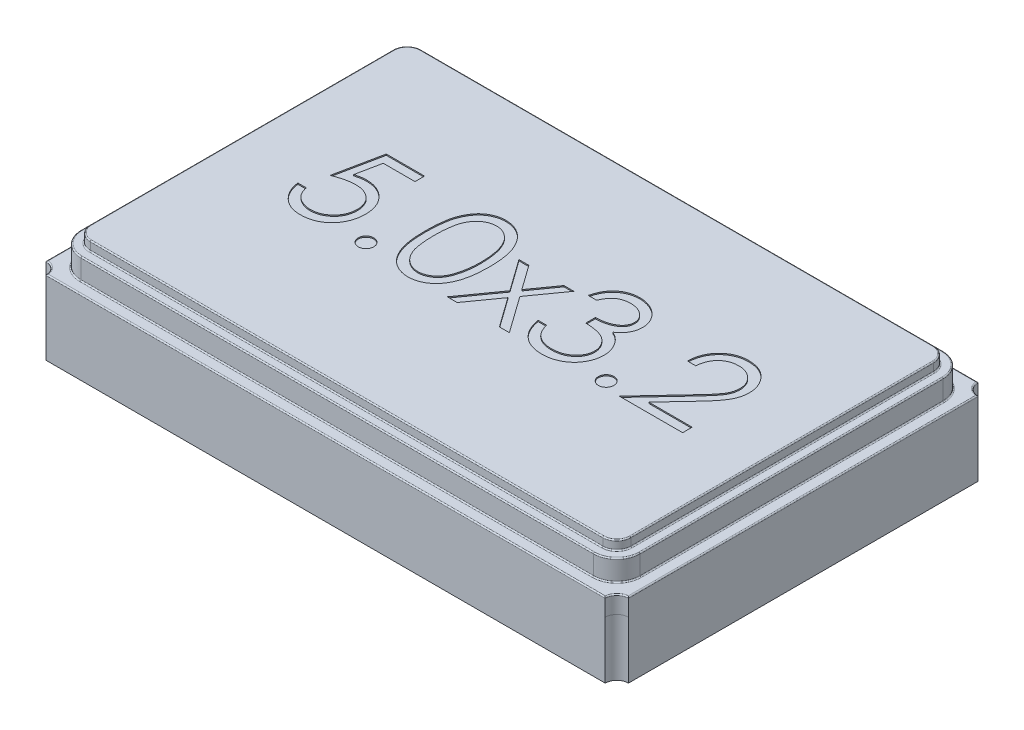
from build123d import *

# Parameters (mm, degrees)
BOSS_EXTRUDE1_DEPTH = 0.64
BOSS_EXTRUDE2_DEPTH = 0.18
BOSS_EXTRUDE3_DEPTH = 0.08
FILLET1_R           = 0.01
CUT_EXTRUDE1_DEPTH  = 0.01


with BuildPart() as part:
    # Sketch1 → Boss-Extrude1 (new body)
    with BuildSketch(Plane(origin=(0, 0, 0), x_dir=(1, 0, 0), z_dir=(0, 1, 0))):
        with BuildLine():
            Line((-2.4, 1.6), (2.4, 1.6))
            ThreePointArc((2.4, 1.6), (2.429289322, 1.529289322), (2.5, 1.5))
            Line((2.5, 1.5), (2.5, -1.5))
            ThreePointArc((2.5, -1.5), (2.429289322, -1.529289322), (2.4, -1.6))
            Line((2.4, -1.6), (-2.4, -1.6))
            ThreePointArc((-2.4, -1.6), (-2.429289322, -1.529289322), (-2.5, -1.5))
            Line((-2.5, -1.5), (-2.5, 1.5))
            ThreePointArc((-2.5, 1.5), (-2.429289322, 1.529289322), (-2.4, 1.6))
        make_face()
    extrude(amount=BOSS_EXTRUDE1_DEPTH)

    # Sketch2 → Boss-Extrude2 (add)
    with BuildSketch(Plane(origin=(0, 0.64, 0), x_dir=(1, 0, 0), z_dir=(0, 1, 0))):
        with BuildLine():
            Line((-2.2, 1.5), (2.2, 1.5))
            ThreePointArc((2.2, 1.5), (2.341421356, 1.441421356), (2.4, 1.3))
            Line((2.4, 1.3), (2.4, -1.3))
            ThreePointArc((2.4, -1.3), (2.341421356, -1.441421356), (2.2, -1.5))
            Line((2.2, -1.5), (-2.2, -1.5))
            ThreePointArc((-2.2, -1.5), (-2.341421356, -1.441421356), (-2.4, -1.3))
            Line((-2.4, -1.3), (-2.4, 1.3))
            ThreePointArc((-2.4, 1.3), (-2.341421356, 1.441421356), (-2.2, 1.5))
        make_face()
    extrude(amount=BOSS_EXTRUDE2_DEPTH)

    # Sketch4 → Boss-Extrude3 (add)
    with BuildSketch(Plane(origin=(0, 0.82, 0), x_dir=(1, 0, 0), z_dir=(0, 1, 0))):
        with BuildLine():
            Line((2.32, -1.3), (2.32, 1.3))
            ThreePointArc((2.32, 1.3), (2.284852814, 1.384852814), (2.2, 1.42))
            Line((2.2, 1.42), (-2.2, 1.42))
            ThreePointArc((-2.2, 1.42), (-2.284852814, 1.384852814), (-2.32, 1.3))
            Line((-2.32, 1.3), (-2.32, -1.3))
            ThreePointArc((-2.32, -1.3), (-2.284852814, -1.384852814), (-2.2, -1.42))
            Line((-2.2, -1.42), (2.2, -1.42))
            ThreePointArc((2.2, -1.42), (2.284852814, -1.384852814), (2.32, -1.3))
        make_face()
    extrude(amount=BOSS_EXTRUDE3_DEPTH)

    # Fillet1
    fillet1_edges = [part.edges().sort_by_distance(p)[0] for p in [
        (2.429289322, 0.64, -1.529289322),
        (0, 0.64, -1.6),
        (-2.429289322, 0.64, -1.529289322),
        (-2.5, 0.64, 0),
        (-2.429289322, 0.64, 1.529289322),
        (0, 0.64, 1.6),
        (2.341421356, 0.64, 1.441421356),
        (2.4, 0.64, 0),
        (2.341421356, 0.64, -1.441421356),
        (0, 0.64, -1.5),
        (-2.341421356, 0.64, -1.441421356),
        (-2.4, 0.64, 0),
        (-2.341421356, 0.64, 1.441421356),
        (0, 0.64, 1.5),
        (2.341421356, 0.82, 1.441421356),
        (2.4, 0.82, 0),
        (2.341421356, 0.82, -1.441421356),
        (0, 0.82, -1.5),
        (-2.341421356, 0.82, -1.441421356),
        (-2.4, 0.82, 0),
        (-2.341421356, 0.82, 1.441421356),
        (0, 0.82, 1.5),
        (2.429289322, 0.64, 1.529289322),
        (2.284852814, 0.82, 1.384852814),
        (2.32, 0.82, 0),
        (2.284852814, 0.82, -1.384852814),
        (0, 0.82, -1.42),
        (-2.284852814, 0.82, -1.384852814),
        (-2.32, 0.82, 0),
        (-2.284852814, 0.82, 1.384852814),
        (0, 0.82, 1.42),
        (2.284852814, 0.9, 1.384852814),
        (2.32, 0.9, 0),
        (2.284852814, 0.9, -1.384852814),
        (0, 0.9, -1.42),
        (-2.284852814, 0.9, -1.384852814),
        (-2.32, 0.9, 0),
        (-2.284852814, 0.9, 1.384852814),
        (0, 0.9, 1.42),
        (2.5, 0.64, 0),
    ]]
    fillet(fillet1_edges, radius=FILLET1_R)

    # Sketch8 → Cut-Extrude1 (cut)
    with BuildSketch(Plane(origin=(0, 0.9, 0), x_dir=(1, 0, 0), z_dir=(0, 1, 0))):
        with BuildLine():
            Line((-1.244778818, 0.493988522), (-1.244778818, 0.41193724))
            Line((-1.244778818, 0.41193724), (-1.516894202, 0.41193724))
            Line((-1.516894202, 0.41193724), (-1.560003177, 0.201520573))
            add(Edge.make_bspline(
                [(-1.560003177, 0.201520573), (-1.551533263, 0.203858921), (-1.535124144, 0.2083891), (-1.510904747, 0.21341899), (-1.487912243, 0.216451092), (-1.472992159, 0.216865106), (-1.465772408, 0.217065445)],
                knots=[0, 0, 0, 0, 1.100273476, 2.13160584, 3.095893838, 4, 4, 4, 4], degree=3))
            add(Edge.make_bspline(
                [(-1.465772408, 0.217065445), (-1.456838981, 0.216872088), (-1.439273633, 0.2164919), (-1.413573303, 0.212841192), (-1.38904007, 0.207094926), (-1.365725242, 0.199067378), (-1.343585688, 0.188802296), (-1.322825103, 0.175979452), (-1.303131865, 0.161000405), (-1.284859272, 0.143778688), (-1.268282288, 0.124825176), (-1.253707204, 0.104446234), (-1.241327184, 0.082839911), (-1.23137044, 0.059799772), (-1.223419735, 0.035580537), (-1.21812785, 0.009927375), (-1.214604031, -0.016917909), (-1.214210343, -0.03527324), (-1.214009587, -0.044633273)],
                knots=[0, 0, 0, 0, 1.052922333, 2.070308379, 3.05430497, 4.020497103, 4.973039431, 5.925935799, 6.892292201, 7.88610001, 8.88166317, 9.857072816, 10.836096531, 11.812156883, 12.81219415, 13.836441305, 14.89672472, 16, 16, 16, 16], degree=3))
            add(Edge.make_bspline(
                [(-1.214009587, -0.044633273), (-1.214161604, -0.051152638), (-1.214463584, -0.064103264), (-1.215999262, -0.083336224), (-1.218955997, -0.102162014), (-1.222925762, -0.120583132), (-1.228078315, -0.138564703), (-1.234315813, -0.156158195), (-1.241949191, -0.173254105), (-1.250322076, -0.190014196), (-1.259749843, -0.206059569), (-1.270213502, -0.221065051), (-1.281268471, -0.235255744), (-1.293163645, -0.248479455), (-1.306009587, -0.260649287), (-1.319650722, -0.271837466), (-1.3339782, -0.282233199), (-1.349213684, -0.2914145), (-1.365017681, -0.299863176), (-1.381618416, -0.30679427), (-1.398638005, -0.312990962), (-1.416321405, -0.317930283), (-1.434628562, -0.321800581), (-1.453589653, -0.32442929), (-1.473105235, -0.326343904), (-1.486333809, -0.326463757), (-1.493015997, -0.326524299)],
                knots=[0, 0, 0, 0, 1.056347294, 2.098418968, 3.122841568, 4.141288669, 5.149314143, 6.15115421, 7.162517403, 8.180376062, 9.185164535, 10.17417709, 11.141909838, 12.097768115, 13.052685741, 14.0056014, 14.954263652, 15.917497458, 16.885230207, 17.854509472, 18.828990115, 19.81800267, 20.826176721, 21.857883937, 22.917946725, 24, 24, 24, 24], degree=3))
            add(Edge.make_bspline(
                [(-1.493015997, -0.326524299), (-1.500987239, -0.326366393), (-1.516669714, -0.326055732), (-1.539645844, -0.322805793), (-1.561752039, -0.318151183), (-1.582810348, -0.311148607), (-1.603009494, -0.302374368), (-1.622077544, -0.291284958), (-1.640501721, -0.278718305), (-1.657533044, -0.26388851), (-1.673340156, -0.247679212), (-1.687490215, -0.230088894), (-1.700092175, -0.211407878), (-1.710944232, -0.191545443), (-1.720200922, -0.170553779), (-1.72747292, -0.148354236), (-1.733342258, -0.125062806), (-1.735825326, -0.109027718), (-1.73708651, -0.100883273)],
                knots=[0, 0, 0, 0, 1.0467383, 2.05933395, 3.04377827, 4.011590433, 4.970194871, 5.932262533, 6.905835911, 7.896367577, 8.894135286, 9.877477877, 10.858688626, 11.851381753, 12.8477658, 13.868841284, 14.917554742, 16, 16, 16, 16], degree=3))
            Line((-1.73708651, -0.100883273), (-1.665291638, -0.100883273))
            add(Edge.make_bspline(
                [(-1.665291638, -0.100883273), (-1.663525111, -0.108512177), (-1.660129747, -0.123175353), (-1.652677005, -0.143776802), (-1.643564805, -0.162135482), (-1.632729525, -0.178494244), (-1.619803804, -0.192759157), (-1.60505422, -0.205471629), (-1.588517597, -0.21694023), (-1.570142002, -0.226499719), (-1.550756155, -0.234652577), (-1.530466507, -0.240081536), (-1.509825514, -0.243898883), (-1.495864744, -0.244281), (-1.488849331, -0.244473017)],
                knots=[0, 0, 0, 0, 1.136247022, 2.183929868, 3.172523383, 4.106158343, 5.02341133, 5.958108904, 6.928429099, 7.938127109, 8.96079061, 9.975095812, 10.982467395, 12, 12, 12, 12], degree=3))
            add(Edge.make_bspline(
                [(-1.488849331, -0.244473017), (-1.482001686, -0.244285411), (-1.468518618, -0.243916012), (-1.448676016, -0.241072809), (-1.429518787, -0.236693936), (-1.411235963, -0.230140826), (-1.393507611, -0.222176319), (-1.376782178, -0.21195573), (-1.360575806, -0.20019344), (-1.345392232, -0.186717639), (-1.331486073, -0.171867423), (-1.319198959, -0.155986876), (-1.308964236, -0.139045883), (-1.300339297, -0.121337733), (-1.293789972, -0.102668349), (-1.289117747, -0.083125223), (-1.286374191, -0.062660085), (-1.285996778, -0.048701386), (-1.285804459, -0.041588402)],
                knots=[0, 0, 0, 0, 1.027316725, 2.022795036, 3.002884548, 3.971462791, 4.93288096, 5.914575861, 6.907176829, 7.935150275, 8.956128384, 9.956726525, 10.942570165, 11.921478529, 12.907843606, 13.90538589, 14.932640048, 16, 16, 16, 16], degree=3))
            add(Edge.make_bspline(
                [(-1.285804459, -0.041588402), (-1.285954968, -0.035171087), (-1.28624957, -0.022610106), (-1.288656557, -0.004233145), (-1.292843294, 0.013154979), (-1.298654466, 0.029638232), (-1.306032639, 0.045232162), (-1.315048939, 0.059952862), (-1.325872573, 0.073606309), (-1.338236433, 0.086198893), (-1.351781128, 0.097820579), (-1.366739698, 0.107727798), (-1.38279911, 0.116062408), (-1.399765876, 0.123255093), (-1.418043567, 0.128420978), (-1.437270226, 0.132299352), (-1.457653473, 0.134542863), (-1.47158963, 0.134854152), (-1.478753177, 0.135014163)],
                knots=[0, 0, 0, 0, 1.045622112, 2.046656509, 3.013763289, 3.955457236, 4.890082067, 5.820317437, 6.762574623, 7.722996705, 8.69280354, 9.665887285, 10.63943826, 11.638615906, 12.663482002, 13.728887084, 14.832589034, 16, 16, 16, 16], degree=3))
            add(Edge.make_bspline(
                [(-1.478753177, 0.135014163), (-1.484954075, 0.134881456), (-1.497757356, 0.134607451), (-1.517396859, 0.132589966), (-1.538034967, 0.12933527), (-1.559592566, 0.124858413), (-1.582134397, 0.118999881), (-1.605612888, 0.111979424), (-1.630077407, 0.103585824), (-1.646561458, 0.097247033), (-1.655035228, 0.093988522)],
                knots=[0, 0, 0, 0, 0.817624296, 1.688186739, 2.600797293, 3.572016777, 4.590301741, 5.671205678, 6.80286297, 8, 8, 8, 8], degree=3))
            Line((-1.655035228, 0.093988522), (-1.572983946, 0.493988522))
            Line((-1.572983946, 0.493988522), (-1.244778818, 0.493988522))
        make_face()
        with BuildLine():
            add(Edge.make_bspline(
                [(-1.003753177, -0.182934555), (-0.999298271, -0.183199279), (-0.99056495, -0.183718239), (-0.977938863, -0.187278622), (-0.966511512, -0.193600601), (-0.956332713, -0.202026379), (-0.947942662, -0.212242531), (-0.941395381, -0.223578739), (-0.937866013, -0.236310531), (-0.937350833, -0.245094457), (-0.93708651, -0.249601222)],
                knots=[0, 0, 0, 0, 1.020151414, 1.999887582, 2.974338812, 3.990962822, 5.007586832, 5.987933904, 6.967670073, 8, 8, 8, 8], degree=3))
            add(Edge.make_bspline(
                [(-0.93708651, -0.249601222), (-0.93735979, -0.253999697), (-0.937898695, -0.262673426), (-0.941387291, -0.275309189), (-0.94799256, -0.286652482), (-0.956274844, -0.297007256), (-0.966514029, -0.305450884), (-0.977965879, -0.311719077), (-0.99053531, -0.315534386), (-0.999293326, -0.316020397), (-1.003753177, -0.316267889)],
                knots=[0, 0, 0, 0, 1.009421747, 1.99056486, 2.972319754, 3.999869655, 5.017953583, 5.993804169, 6.978383603, 8, 8, 8, 8], degree=3))
            add(Edge.make_bspline(
                [(-1.003753177, -0.316267889), (-1.008216241, -0.316029352), (-1.016929311, -0.315563666), (-1.029451824, -0.311640739), (-1.040973417, -0.305509663), (-1.051210608, -0.296991512), (-1.059562259, -0.286705765), (-1.065876632, -0.275231069), (-1.069668666, -0.262709597), (-1.07016738, -0.254006822), (-1.070419844, -0.249601222)],
                knots=[0, 0, 0, 0, 1.022052826, 1.995314843, 2.982371812, 4.00089066, 5.028879526, 6.005146991, 6.990147033, 8, 8, 8, 8], degree=3))
            add(Edge.make_bspline(
                [(-1.070419844, -0.249601222), (-1.070177078, -0.245087078), (-1.069703108, -0.236273766), (-1.065868671, -0.223656827), (-1.059611252, -0.212189755), (-1.051152876, -0.202041966), (-1.040975894, -0.193542011), (-1.029479618, -0.187355772), (-1.016899152, -0.183689392), (-1.008211166, -0.183190531), (-1.003753177, -0.182934555)],
                knots=[0, 0, 0, 0, 1.032775665, 2.016367738, 2.991239715, 4.008302682, 5.025365648, 6.011011707, 6.979408107, 8, 8, 8, 8], degree=3))
        make_face()
        with BuildLine():
            add(Edge.make_bspline(
                [(-0.834522408, 0.093668009), (-0.834447432, 0.106490269), (-0.834301791, 0.131397694), (-0.83268158, 0.167691326), (-0.829990074, 0.201739392), (-0.826301531, 0.233543522), (-0.82181285, 0.263111925), (-0.815820739, 0.290365584), (-0.809006384, 0.315430637), (-0.801108682, 0.338388819), (-0.792197187, 0.359549437), (-0.782497928, 0.379303769), (-0.771625975, 0.397621925), (-0.76020268, 0.414796277), (-0.747765635, 0.430545693), (-0.734668769, 0.445092587), (-0.720400912, 0.458100759), (-0.705447081, 0.469951342), (-0.689671889, 0.480339793), (-0.673524994, 0.489490133), (-0.656895256, 0.497307245), (-0.639737271, 0.503453631), (-0.622205258, 0.508530396), (-0.604237928, 0.512002155), (-0.585805617, 0.514186591), (-0.573364146, 0.51439543), (-0.567054459, 0.514501342)],
                knots=[0, 0, 0, 0, 1.646270934, 3.197905019, 4.663502075, 6.030701355, 7.308322542, 8.50163776, 9.611534131, 10.641858119, 11.616356847, 12.558055219, 13.465016945, 14.349605745, 15.204443733, 16.039544428, 16.859896111, 17.680448484, 18.487036065, 19.28249412, 20.06191084, 20.843045899, 21.620316918, 22.403196591, 23.190181807, 24, 24, 24, 24], degree=3))
            add(Edge.make_bspline(
                [(-0.567054459, 0.514501342), (-0.560692064, 0.514389841), (-0.548039262, 0.514168102), (-0.52933289, 0.512036915), (-0.511058677, 0.508500658), (-0.493294531, 0.50349015), (-0.475894534, 0.497273995), (-0.458994784, 0.489482654), (-0.442490308, 0.480413199), (-0.426643385, 0.469756312), (-0.411280045, 0.457874649), (-0.396777653, 0.444443182), (-0.383134891, 0.429597532), (-0.370180535, 0.413496535), (-0.358282113, 0.395831372), (-0.346951043, 0.37690929), (-0.336808863, 0.356399378), (-0.327040937, 0.334643843), (-0.318609626, 0.311040721), (-0.311005913, 0.285723061), (-0.304862149, 0.258391818), (-0.299744601, 0.229190391), (-0.295780053, 0.198011538), (-0.292892592, 0.164922094), (-0.291367315, 0.12990029), (-0.291080069, 0.105955639), (-0.290932664, 0.093668009)],
                knots=[0, 0, 0, 0, 0.810914788, 1.612654377, 2.396697861, 3.181598691, 3.963628158, 4.749916497, 5.551656086, 6.361998678, 7.18212741, 8.025565596, 8.878627764, 9.750805457, 10.657531673, 11.591944965, 12.560506719, 13.57287815, 14.630710178, 15.753379473, 16.941251878, 18.199788006, 19.531962791, 20.947069417, 22.433333509, 24, 24, 24, 24], degree=3))
            add(Edge.make_bspline(
                [(-0.290932664, 0.093668009), (-0.291081598, 0.081433973), (-0.291371789, 0.057596452), (-0.292875493, 0.022732229), (-0.295837466, -0.010181609), (-0.299542606, -0.041224001), (-0.304674255, -0.070265742), (-0.310984007, -0.09740733), (-0.317989795, -0.122765975), (-0.326637748, -0.146133932), (-0.336103053, -0.167837183), (-0.346401384, -0.18810396), (-0.357434487, -0.207113398), (-0.369454772, -0.22471334), (-0.38226698, -0.241028462), (-0.396145332, -0.255770776), (-0.410698609, -0.269295501), (-0.426107161, -0.281330158), (-0.44220123, -0.291863828), (-0.458649019, -0.301284137), (-0.475742363, -0.308880181), (-0.493093895, -0.315402476), (-0.510951808, -0.320385437), (-0.52929384, -0.32383089), (-0.548026694, -0.326247312), (-0.560689909, -0.32643165), (-0.567054459, -0.326524299)],
                knots=[0, 0, 0, 0, 1.561518951, 3.042555995, 4.452378317, 5.7783523, 7.031515105, 8.214008947, 9.334062868, 10.386615937, 11.391082383, 12.354592575, 13.286541444, 14.194233754, 15.072674879, 15.931287219, 16.775624067, 17.606195743, 18.42308326, 19.229000347, 20.022332153, 20.807536673, 21.593273796, 22.3848459, 23.188221202, 24, 24, 24, 24], degree=3))
            add(Edge.make_bspline(
                [(-0.567054459, -0.326524299), (-0.573363971, -0.326417703), (-0.585805096, -0.326207518), (-0.604239936, -0.324032951), (-0.622133066, -0.320536836), (-0.639572782, -0.315641612), (-0.656648556, -0.309649649), (-0.673127708, -0.301843093), (-0.689193464, -0.292852449), (-0.704802962, -0.282613495), (-0.719662885, -0.270882825), (-0.733856852, -0.25790813), (-0.747028285, -0.243365636), (-0.759287507, -0.227484968), (-0.770938727, -0.210412227), (-0.781656298, -0.191914313), (-0.791569636, -0.172064574), (-0.800631005, -0.150734765), (-0.808664986, -0.127613639), (-0.815761605, -0.102436684), (-0.821364841, -0.074981681), (-0.826160945, -0.04546914), (-0.830029375, -0.013772242), (-0.832670364, 0.020126222), (-0.834302664, 0.056205127), (-0.834447823, 0.080952503), (-0.834522408, 0.093668009)],
                knots=[0, 0, 0, 0, 0.810891512, 1.598919785, 2.382837074, 3.152667961, 3.926044502, 4.706494248, 5.493654104, 6.291793342, 7.103789334, 7.925228297, 8.761435821, 9.622817696, 10.50288917, 11.416980706, 12.369136599, 13.353924996, 14.394355917, 15.514179734, 16.714354668, 17.994756427, 19.357759367, 20.818452758, 22.365282078, 24, 24, 24, 24], degree=3))
        make_face()
        with BuildLine():
            add(Edge.make_bspline(
                [(-0.762727536, 0.093988522), (-0.762700234, 0.083303105), (-0.762647245, 0.062564809), (-0.761262971, 0.032429206), (-0.759377204, 0.004321703), (-0.756944907, -0.021793392), (-0.753332805, -0.04582768), (-0.749285539, -0.067946465), (-0.744360261, -0.08803269), (-0.738532829, -0.10622419), (-0.731895321, -0.122829691), (-0.724648266, -0.138281398), (-0.716862958, -0.15276184), (-0.708150009, -0.166140951), (-0.698660852, -0.17846236), (-0.688609821, -0.18994415), (-0.677621802, -0.20018346), (-0.662420947, -0.212463884), (-0.642353181, -0.225153972), (-0.617068506, -0.236204507), (-0.591087145, -0.243149068), (-0.573452574, -0.244032212), (-0.564650613, -0.244473017)],
                knots=[0, 0, 0, 0, 1.459021318, 2.831673884, 4.118529203, 5.306027144, 6.411944654, 7.436330062, 8.375795394, 9.233974572, 10.042671642, 10.816086306, 11.563610507, 12.285937304, 12.993564865, 13.685989202, 14.367179055, 15.041617293, 16.353048772, 17.594441528, 18.799311195, 20, 20, 20, 20], degree=3))
            add(Edge.make_bspline(
                [(-0.564650613, -0.244473017), (-0.555791716, -0.24410781), (-0.538092214, -0.24337815), (-0.512233061, -0.236338438), (-0.487128999, -0.225716829), (-0.467455413, -0.2131574), (-0.452487974, -0.201196639), (-0.441764091, -0.190999005), (-0.431921337, -0.179580521), (-0.422586005, -0.167260682), (-0.414023931, -0.153804114), (-0.406238071, -0.139275525), (-0.399133306, -0.12363457), (-0.395085524, -0.112715773), (-0.393015997, -0.107133273)],
                knots=[0, 0, 0, 0, 1.353760809, 2.704726607, 4.075137775, 5.516104923, 6.260822281, 7.007110065, 7.778089737, 8.566572457, 9.372053459, 10.217411131, 11.088608312, 12, 12, 12, 12], degree=3))
            add(Edge.make_bspline(
                [(-0.393015997, -0.107133273), (-0.390604165, -0.099995047), (-0.38570711, -0.085501387), (-0.379395847, -0.063018266), (-0.37442547, -0.039429063), (-0.369953844, -0.014874751), (-0.366901717, 0.010825752), (-0.364445074, 0.037592926), (-0.36299806, 0.065446952), (-0.362818688, 0.084371521), (-0.362727536, 0.093988522)],
                knots=[0, 0, 0, 0, 0.884706709, 1.796334032, 2.740027952, 3.714592787, 4.726048262, 5.777819803, 6.87074269, 8, 8, 8, 8], degree=3))
            add(Edge.make_bspline(
                [(-0.362727536, 0.093988522), (-0.362853293, 0.103603967), (-0.363099302, 0.122413833), (-0.364039642, 0.149960846), (-0.366467888, 0.176124905), (-0.369164829, 0.201018728), (-0.373141337, 0.224504511), (-0.377428835, 0.246778867), (-0.383189113, 0.267565844), (-0.389342204, 0.287190891), (-0.39638458, 0.305431041), (-0.404136748, 0.322371335), (-0.412416007, 0.338093557), (-0.421408519, 0.352554573), (-0.431007532, 0.365819154), (-0.441466401, 0.377621347), (-0.452370258, 0.38832694), (-0.467642757, 0.400546955), (-0.487636881, 0.413006771), (-0.512515886, 0.424473231), (-0.538406319, 0.431057983), (-0.555908822, 0.431986369), (-0.564650613, 0.43245006)],
                knots=[0, 0, 0, 0, 1.31362396, 2.569729283, 3.763502607, 4.902122613, 5.988968491, 7.01645872, 7.998833611, 8.933434873, 9.825090667, 10.667526885, 11.477055099, 12.250526234, 12.991942729, 13.710640831, 14.402115721, 15.076753259, 16.378508321, 17.609869233, 18.806226677, 20, 20, 20, 20], degree=3))
            add(Edge.make_bspline(
                [(-0.564650613, 0.43245006), (-0.573498748, 0.431985729), (-0.591211138, 0.431056222), (-0.61737067, 0.424497764), (-0.642445951, 0.413066229), (-0.662387202, 0.400505687), (-0.677670353, 0.388542644), (-0.688432112, 0.378168598), (-0.698522666, 0.366820882), (-0.70781814, 0.354386159), (-0.716524262, 0.341022646), (-0.724519922, 0.326625214), (-0.731723883, 0.311120903), (-0.738371777, 0.29452286), (-0.744216985, 0.27633293), (-0.749038463, 0.256271446), (-0.753492646, 0.234223013), (-0.756645851, 0.210058554), (-0.759448995, 0.183936919), (-0.761250446, 0.155759247), (-0.762651876, 0.125573103), (-0.762701811, 0.104727581), (-0.762727536, 0.093988522)],
                knots=[0, 0, 0, 0, 1.207732386, 2.417664972, 3.655092373, 4.956220595, 5.625982001, 6.301752483, 6.994047911, 7.697131622, 8.419323945, 9.170223765, 9.943494443, 10.752040957, 11.610060368, 12.549350801, 13.567764191, 14.679664412, 15.874934091, 17.154273443, 18.533957287, 20, 20, 20, 20], degree=3))
        make_face(mode=Mode.SUBTRACT)
        Polygon((-0.219137792, 0.278603906), (-0.133721126, 0.278603906), (0.016759644, 0.06770647), (0.167240413, 0.278603906), (0.25265708, 0.278603906), (0.059548105, 0.007930829), (0.28342631, -0.306011478), (0.198009644, -0.306011478), (0.016759644, -0.052005068), (-0.164490356, -0.306011478), (-0.249907023, -0.306011478), (-0.025868561, 0.007930829), align=None)
        with BuildLine():
            Line((0.416759644, 0.309373137), (0.344964772, 0.309373137))
            add(Edge.make_bspline(
                [(0.344964772, 0.309373137), (0.346909812, 0.317426276), (0.350712206, 0.333169505), (0.35864308, 0.355662593), (0.36728291, 0.376947969), (0.377657563, 0.396627072), (0.388973849, 0.415095392), (0.401939043, 0.431934049), (0.415954979, 0.447571299), (0.431457825, 0.46144861), (0.447715805, 0.474014948), (0.464958004, 0.484729247), (0.482837522, 0.493946196), (0.501478238, 0.501539392), (0.520935649, 0.507259512), (0.541033848, 0.511409639), (0.561825506, 0.514104751), (0.575939241, 0.514367782), (0.583105798, 0.514501342)],
                knots=[0, 0, 0, 0, 1.162005537, 2.271625781, 3.343758855, 4.383309926, 5.390229558, 6.379919256, 7.361854164, 8.333198761, 9.295911338, 10.242430842, 11.177959212, 12.116337295, 13.062827104, 14.020064771, 14.994644689, 16, 16, 16, 16], degree=3))
            add(Edge.make_bspline(
                [(0.583105798, 0.514501342), (0.593547567, 0.514186089), (0.614203341, 0.513562461), (0.64454918, 0.507867732), (0.673812453, 0.498856274), (0.701672853, 0.486405136), (0.727551352, 0.471048036), (0.750576766, 0.452770382), (0.770436997, 0.431924827), (0.787098569, 0.408900241), (0.800144283, 0.384293267), (0.809764025, 0.358967517), (0.81562041, 0.332983067), (0.816379394, 0.315438546), (0.816759644, 0.306648778)],
                knots=[0, 0, 0, 0, 1.083050992, 2.142477498, 3.193116406, 4.255571735, 5.30263384, 6.308962982, 7.297363603, 8.282367274, 9.249857812, 10.179914175, 11.08814088, 12, 12, 12, 12], degree=3))
            add(Edge.make_bspline(
                [(0.816759644, 0.306648778), (0.81649368, 0.298190082), (0.81597323, 0.281637727), (0.811554098, 0.257472813), (0.804117238, 0.23469759), (0.793815578, 0.213216182), (0.780480366, 0.19316479), (0.764326607, 0.1744983), (0.745240284, 0.157133921), (0.730776527, 0.147186613), (0.723330156, 0.142065445)],
                knots=[0, 0, 0, 0, 1.024540389, 2.004866551, 2.965041327, 3.920577974, 4.882998113, 5.874504559, 6.905732034, 8, 8, 8, 8], degree=3))
            add(Edge.make_bspline(
                [(0.723330156, 0.142065445), (0.731840272, 0.137956148), (0.748701272, 0.129814444), (0.77168425, 0.113847413), (0.792547764, 0.095411677), (0.8041829, 0.081024785), (0.810028874, 0.073796214)],
                knots=[0, 0, 0, 0, 1.015518401, 2.012035669, 3.001164323, 4, 4, 4, 4], degree=3))
            add(Edge.make_bspline(
                [(0.810028874, 0.073796214), (0.813878324, 0.068525871), (0.821514186, 0.05807149), (0.830939451, 0.041263164), (0.839490106, 0.024268538), (0.846153013, 0.006632102), (0.851312754, -0.01144173), (0.85500099, -0.029983992), (0.857292222, -0.049009825), (0.857620348, -0.061881249), (0.857785285, -0.068351222)],
                knots=[0, 0, 0, 0, 1.025084078, 2.033381695, 3.024893161, 4.013698104, 4.991890475, 5.976764909, 6.982997093, 8, 8, 8, 8], degree=3))
            add(Edge.make_bspline(
                [(0.857785285, -0.068351222), (0.85737511, -0.079553444), (0.856556691, -0.10190517), (0.849241474, -0.134927964), (0.837901305, -0.167208078), (0.821796863, -0.198082327), (0.802170003, -0.226969272), (0.778819758, -0.252815285), (0.752011436, -0.275032109), (0.722113002, -0.293594447), (0.689720515, -0.308432829), (0.655074666, -0.318731673), (0.618674654, -0.32543933), (0.593712986, -0.326158615), (0.581022464, -0.326524299)],
                knots=[0, 0, 0, 0, 0.955779014, 1.907060117, 2.875433937, 3.871313158, 4.872415639, 5.851225146, 6.836215519, 7.83643374, 8.849228613, 9.86973379, 10.916971861, 12, 12, 12, 12], degree=3))
            add(Edge.make_bspline(
                [(0.581022464, -0.326524299), (0.572469481, -0.32632585), (0.555640063, -0.325935369), (0.530898692, -0.323265975), (0.507282303, -0.318390545), (0.484758967, -0.311829789), (0.463308673, -0.303511677), (0.442996877, -0.293153117), (0.423698616, -0.280967631), (0.405595999, -0.266811383), (0.388691183, -0.250975648), (0.373433418, -0.233179303), (0.359568322, -0.213751325), (0.347467147, -0.192466055), (0.336578701, -0.169598567), (0.327623054, -0.144856053), (0.319740638, -0.118459705), (0.316075846, -0.100064793), (0.314195541, -0.090626863)],
                knots=[0, 0, 0, 0, 1.048658725, 2.063410685, 3.046034179, 4.001477787, 4.936774919, 5.862367409, 6.792675028, 7.730719943, 8.675894397, 9.627829632, 10.600096036, 11.597688215, 12.626045268, 13.701542398, 14.82072376, 16, 16, 16, 16], degree=3))
            Line((0.314195541, -0.090626863), (0.385990413, -0.090626863))
            add(Edge.make_bspline(
                [(0.385990413, -0.090626863), (0.38786088, -0.096786638), (0.3914991, -0.108767934), (0.397692082, -0.126011432), (0.404747687, -0.141818987), (0.412316729, -0.156306558), (0.420266088, -0.169616822), (0.429160928, -0.18139782), (0.438342447, -0.192167009), (0.445263442, -0.198234349), (0.448650669, -0.201203786)],
                knots=[0, 0, 0, 0, 1.198163088, 2.33053128, 3.407730985, 4.417276592, 5.372219308, 6.28897303, 7.162600585, 8, 8, 8, 8], degree=3))
            add(Edge.make_bspline(
                [(0.448650669, -0.201203786), (0.453129887, -0.20465712), (0.462074495, -0.211553127), (0.476650091, -0.220353499), (0.491979208, -0.227978876), (0.508393991, -0.233803721), (0.525540224, -0.238735758), (0.54369505, -0.241963305), (0.5626983, -0.244177744), (0.575673789, -0.244373157), (0.582304515, -0.244473017)],
                knots=[0, 0, 0, 0, 0.946170439, 1.889420265, 2.845303464, 3.807233317, 4.801018734, 5.828864929, 6.890507805, 8, 8, 8, 8], degree=3))
            add(Edge.make_bspline(
                [(0.582304515, -0.244473017), (0.58979103, -0.244332239), (0.604430264, -0.244056959), (0.625791375, -0.241525369), (0.646113077, -0.237838417), (0.665169746, -0.232144021), (0.683211005, -0.225108398), (0.699983953, -0.216274476), (0.715708777, -0.205909969), (0.73018407, -0.194129589), (0.743200186, -0.181233248), (0.754660646, -0.167744546), (0.764403426, -0.153720356), (0.772262529, -0.139083071), (0.77846837, -0.123893305), (0.782693101, -0.108108429), (0.78563059, -0.091857626), (0.785869816, -0.080811004), (0.785990413, -0.075242248)],
                knots=[0, 0, 0, 0, 1.217147791, 2.380027433, 3.494444702, 4.572153297, 5.609568379, 6.639424714, 7.649109417, 8.668170816, 9.669597737, 10.625200337, 11.543417969, 12.441394052, 13.322311151, 14.205496177, 15.095365482, 16, 16, 16, 16], degree=3))
            add(Edge.make_bspline(
                [(0.785990413, -0.075242248), (0.78564063, -0.067788227), (0.784942804, -0.052917277), (0.779615128, -0.031038974), (0.770851959, -0.009959337), (0.758583957, 0.009961986), (0.743650076, 0.02842505), (0.72619524, 0.044898531), (0.706074502, 0.058491695), (0.687555675, 0.067883388), (0.671152211, 0.074291862), (0.657114409, 0.078560425), (0.641398614, 0.082174975), (0.624194877, 0.08553778), (0.60537357, 0.088399803), (0.584955184, 0.090786503), (0.562935582, 0.092696227), (0.547691887, 0.093549049), (0.539836567, 0.093988522)],
                knots=[0, 0, 0, 0, 1.07054697, 2.135767047, 3.216561865, 4.33974944, 5.486079747, 6.621378074, 7.775625952, 8.963672916, 9.598146892, 10.304877434, 11.070270905, 11.915000392, 12.823868403, 13.805723172, 14.86925407, 16, 16, 16, 16], degree=3))
            Line((0.539836567, 0.093988522), (0.539836567, 0.176039804))
            add(Edge.make_bspline(
                [(0.539836567, 0.176039804), (0.549733976, 0.176207759), (0.56912057, 0.176536742), (0.597439268, 0.180515715), (0.624518882, 0.186019859), (0.64975928, 0.19445076), (0.6727647, 0.204242828), (0.692723467, 0.215637619), (0.709355957, 0.228303847), (0.722581345, 0.242437015), (0.732530883, 0.25759474), (0.73980558, 0.273392833), (0.744102797, 0.289969761), (0.744676435, 0.301282828), (0.744964772, 0.306969291)],
                knots=[0, 0, 0, 0, 1.321986639, 2.589447074, 3.816329219, 5.01088745, 6.139805852, 7.153945165, 8.075214402, 8.924034688, 9.728124013, 10.488707548, 11.240355623, 12, 12, 12, 12], degree=3))
            add(Edge.make_bspline(
                [(0.744964772, 0.306969291), (0.744870049, 0.311147061), (0.744681603, 0.319458537), (0.742305083, 0.33160141), (0.738733873, 0.343373055), (0.733824221, 0.354723411), (0.727252747, 0.36557376), (0.719388522, 0.376016605), (0.710024384, 0.385992326), (0.699293996, 0.395290685), (0.687771298, 0.404152225), (0.675142778, 0.411675342), (0.661789207, 0.418108499), (0.6476958, 0.423413528), (0.632816822, 0.427404222), (0.61722218, 0.430269557), (0.600882138, 0.432061021), (0.589734313, 0.432318945), (0.584067336, 0.43245006)],
                knots=[0, 0, 0, 0, 0.884392785, 1.759457502, 2.611959086, 3.489218968, 4.37281399, 5.2945488, 6.255912374, 7.266815255, 8.301784654, 9.332968512, 10.37626691, 11.440494194, 12.520033166, 13.637162961, 14.798855837, 16, 16, 16, 16], degree=3))
            add(Edge.make_bspline(
                [(0.584067336, 0.43245006), (0.574958383, 0.432132034), (0.55716648, 0.431510856), (0.531517356, 0.426070168), (0.507672937, 0.417389463), (0.489446956, 0.40702763), (0.475988082, 0.396798959), (0.466370496, 0.387865842), (0.456925808, 0.37793834), (0.448275368, 0.366404997), (0.43952703, 0.354046873), (0.431562559, 0.340235746), (0.423823201, 0.325331885), (0.419159761, 0.31479574), (0.416759644, 0.309373137)],
                knots=[0, 0, 0, 0, 1.472543308, 2.876219568, 4.221790263, 5.565193594, 6.249813518, 6.953379497, 7.687249741, 8.463570142, 9.283606569, 10.136032583, 11.040678096, 12, 12, 12, 12], degree=3))
        make_face()
        with BuildLine():
            add(Edge.make_bspline(
                [(1.057785285, -0.182934555), (1.06224019, -0.183199279), (1.070973512, -0.183718239), (1.083599598, -0.187278622), (1.095026949, -0.193600601), (1.105205748, -0.202026379), (1.1135958, -0.212242531), (1.12014308, -0.223578739), (1.123672448, -0.236310531), (1.124187628, -0.245094457), (1.124451951, -0.249601222)],
                knots=[0, 0, 0, 0, 1.020151414, 1.999887582, 2.974338812, 3.990962822, 5.007586832, 5.987933904, 6.967670073, 8, 8, 8, 8], degree=3))
            add(Edge.make_bspline(
                [(1.124451951, -0.249601222), (1.124178671, -0.253999697), (1.123639767, -0.262673426), (1.120151171, -0.275309189), (1.113545902, -0.286652482), (1.105263618, -0.297007256), (1.095024433, -0.305450884), (1.083572582, -0.311719077), (1.071003152, -0.315534386), (1.062245135, -0.316020397), (1.057785285, -0.316267889)],
                knots=[0, 0, 0, 0, 1.009421747, 1.99056486, 2.972319754, 3.999869655, 5.017953583, 5.993804169, 6.978383603, 8, 8, 8, 8], degree=3))
            add(Edge.make_bspline(
                [(1.057785285, -0.316267889), (1.053322221, -0.316029352), (1.04460915, -0.315563666), (1.032086637, -0.311640739), (1.020565044, -0.305509663), (1.010327853, -0.296991512), (1.001976203, -0.286705765), (0.995661829, -0.275231069), (0.991869795, -0.262709597), (0.991371082, -0.254006822), (0.991118618, -0.249601222)],
                knots=[0, 0, 0, 0, 1.022052826, 1.995314843, 2.982371812, 4.00089066, 5.028879526, 6.005146991, 6.990147033, 8, 8, 8, 8], degree=3))
            add(Edge.make_bspline(
                [(0.991118618, -0.249601222), (0.991361384, -0.245087078), (0.991835354, -0.236273766), (0.99566979, -0.223656827), (1.00192721, -0.212189755), (1.010385586, -0.202041966), (1.020562568, -0.193542011), (1.032058843, -0.187355772), (1.04463931, -0.183689392), (1.053327296, -0.183190531), (1.057785285, -0.182934555)],
                knots=[0, 0, 0, 0, 1.032775665, 2.016367738, 2.991239715, 4.008302682, 5.025365648, 6.011011707, 6.979408107, 8, 8, 8, 8], degree=3))
        make_face()
        with BuildLine():
            Line((1.329580156, 0.247834675), (1.257785285, 0.247834675))
            add(Edge.make_bspline(
                [(1.257785285, 0.247834675), (1.258253205, 0.25735945), (1.259172189, 0.276065853), (1.263475798, 0.303339889), (1.269633713, 0.329409557), (1.278340331, 0.354065537), (1.289153194, 0.377525836), (1.302120058, 0.399697268), (1.317478652, 0.420495254), (1.334897334, 0.43972699), (1.35381588, 0.457369863), (1.374228667, 0.472605347), (1.395678959, 0.485477958), (1.418101678, 0.496239385), (1.441749807, 0.504317064), (1.466408746, 0.510310581), (1.492186834, 0.513916603), (1.509750268, 0.514304211), (1.518682721, 0.514501342)],
                knots=[0, 0, 0, 0, 1.10065271, 2.161652631, 3.183658789, 4.190468796, 5.17591951, 6.163126047, 7.15150782, 8.156236427, 9.156009102, 10.134482811, 11.092018607, 12.041330605, 13.001268258, 13.972401359, 14.968799086, 16, 16, 16, 16], degree=3))
            add(Edge.make_bspline(
                [(1.518682721, 0.514501342), (1.527454852, 0.514295981), (1.544691776, 0.513892453), (1.569848808, 0.510427075), (1.593797904, 0.504999511), (1.616492251, 0.497384558), (1.63775078, 0.487148118), (1.65773319, 0.474851538), (1.676677375, 0.460629862), (1.693730354, 0.443886133), (1.709389344, 0.426011302), (1.722898431, 0.406928353), (1.734467154, 0.387218802), (1.744110052, 0.366732356), (1.751208598, 0.345276121), (1.756597903, 0.323162474), (1.759644169, 0.300162518), (1.760111694, 0.284595305), (1.760349387, 0.276680829)],
                knots=[0, 0, 0, 0, 1.111607364, 2.184268762, 3.212621178, 4.221274766, 5.211760367, 6.196651075, 7.1921475, 8.207485113, 9.220403448, 10.201281604, 11.166441695, 12.114753415, 13.065576456, 14.026450734, 14.996634279, 16, 16, 16, 16], degree=3))
            add(Edge.make_bspline(
                [(1.760349387, 0.276680829), (1.759962356, 0.265538467), (1.759195085, 0.243449275), (1.752631799, 0.210988735), (1.742381167, 0.179538811), (1.730038914, 0.154227428), (1.71758807, 0.1338312), (1.706368068, 0.117038354), (1.693233254, 0.098957104), (1.677992455, 0.079647998), (1.660960941, 0.058959791), (1.641984447, 0.036904981), (1.620927651, 0.013711433), (1.606148565, -0.002129847), (1.598490413, -0.010338402)],
                knots=[0, 0, 0, 0, 1.184426356, 2.348067706, 3.509069118, 4.696110526, 5.333549288, 6.050745305, 6.844228056, 7.710549037, 8.667450064, 9.695053472, 10.805634456, 12, 12, 12, 12], degree=3))
            Line((1.598490413, -0.010338402), (1.398330156, -0.223960196))
            Line((1.398330156, -0.223960196), (1.770605798, -0.223960196))
            Line((1.770605798, -0.223960196), (1.770605798, -0.306011478))
            Line((1.770605798, -0.306011478), (1.227016054, -0.306011478))
            Line((1.227016054, -0.306011478), (1.537272464, 0.025078265))
            add(Edge.make_bspline(
                [(1.537272464, 0.025078265), (1.544826267, 0.032963592), (1.559335576, 0.048109692), (1.579857308, 0.070222369), (1.598289077, 0.09073655), (1.614750195, 0.109613475), (1.628883568, 0.127129262), (1.641425792, 0.142716623), (1.65147507, 0.157060497), (1.662381446, 0.173686923), (1.672944642, 0.193986881), (1.682021752, 0.218794582), (1.687556574, 0.244332239), (1.688220537, 0.261589848), (1.688554515, 0.270270573)],
                knots=[0, 0, 0, 0, 1.329631726, 2.553950428, 3.673215718, 4.687767853, 5.603093632, 6.413772471, 7.123043292, 7.734684054, 8.834405432, 9.900288307, 10.943827018, 12, 12, 12, 12], degree=3))
            add(Edge.make_bspline(
                [(1.688554515, 0.270270573), (1.688409203, 0.275729178), (1.68812282, 0.286487041), (1.685595346, 0.302259786), (1.681775802, 0.317474601), (1.6763026, 0.332178285), (1.669078202, 0.346223005), (1.660284287, 0.359625858), (1.650137987, 0.372583336), (1.638400554, 0.384732661), (1.625506492, 0.395859794), (1.611884949, 0.405716728), (1.597473497, 0.413954239), (1.582332898, 0.420707038), (1.566505362, 0.426004268), (1.549960277, 0.4296748), (1.532743359, 0.431979368), (1.520987131, 0.432291179), (1.514996823, 0.43245006)],
                knots=[0, 0, 0, 0, 0.991446411, 1.95395049, 2.89581595, 3.838931463, 4.798493298, 5.75982156, 6.748411868, 7.785213223, 8.824556874, 9.840280684, 10.836137867, 11.835679398, 12.848801643, 13.863922112, 14.911575587, 16, 16, 16, 16], degree=3))
            add(Edge.make_bspline(
                [(1.514996823, 0.43245006), (1.508740633, 0.432286624), (1.496454508, 0.431965663), (1.478415872, 0.429720483), (1.461207694, 0.425847148), (1.444786688, 0.420549622), (1.429125068, 0.413816239), (1.414299001, 0.405429555), (1.400341769, 0.395421899), (1.387227135, 0.384075486), (1.37514394, 0.371442892), (1.364527511, 0.357360615), (1.355251165, 0.342085777), (1.347157626, 0.325659594), (1.340584897, 0.307933016), (1.335562462, 0.288968969), (1.331588326, 0.268849796), (1.330260664, 0.254956062), (1.329580156, 0.247834675)],
                knots=[0, 0, 0, 0, 1.031018746, 2.02475058, 2.990194455, 3.934040569, 4.864654155, 5.795059489, 6.735614925, 7.690564532, 8.649604399, 9.611025574, 10.590972636, 11.591080095, 12.624614302, 13.701020113, 14.821632451, 16, 16, 16, 16], degree=3))
        make_face()
    extrude(amount=-CUT_EXTRUDE1_DEPTH, mode=Mode.SUBTRACT)


solid = part.part
